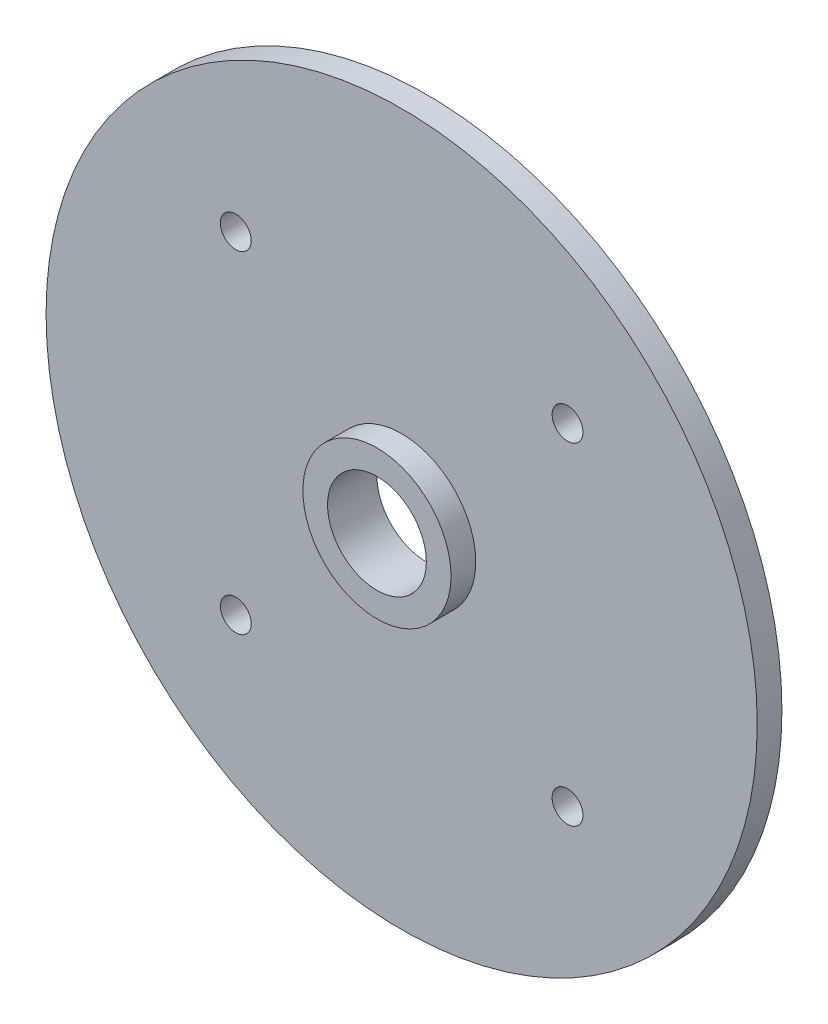
from build123d import *

# Parameters (mm, degrees)
SKETCH1_R             = 6
BOSS_EXTRUDE1_DEPTH   = 2
SKETCH2_R             = 28.8
BOSS_EXTRUDE2_DEPTH   = 2
SKETCH3_R             = 4
CUT_EXTRUDE1_DEPTH    = 5
M3X0_5_TAPPED_HOLE1_D = 2.5


with BuildPart() as part:
    # Sketch1 → Boss-Extrude1 (new body)
    with BuildSketch(Plane.XY):
        with Locations((0, -108.5)):
            Circle(SKETCH1_R)
    extrude(amount=-BOSS_EXTRUDE1_DEPTH)

    # Sketch2 → Boss-Extrude2 (add)
    with BuildSketch(Plane(origin=(0, 0, -2), x_dir=(-1, 0, 0), z_dir=(0, 0, -1))):
        with Locations((0, -108.5)):
            Circle(SKETCH2_R)
    extrude(amount=BOSS_EXTRUDE2_DEPTH)

    # Sketch3 → Cut-Extrude1 (cut, through all)
    with BuildSketch(Plane.XY):
        with Locations((0, -108.5)):
            Circle(SKETCH3_R)
    extrude(amount=-CUT_EXTRUDE1_DEPTH, mode=Mode.SUBTRACT)

    # M3x0.5 Tapped Hole1 (through all)
    with Locations(Plane.XY.offset(-2)):
        with Locations((-13.435028843, -95.064971157), (13.435028843, -95.064971157), (13.435028843, -121.935028843), (-13.435028843, -121.935028843)):
            Hole(M3X0_5_TAPPED_HOLE1_D / 2)


solid = part.part
